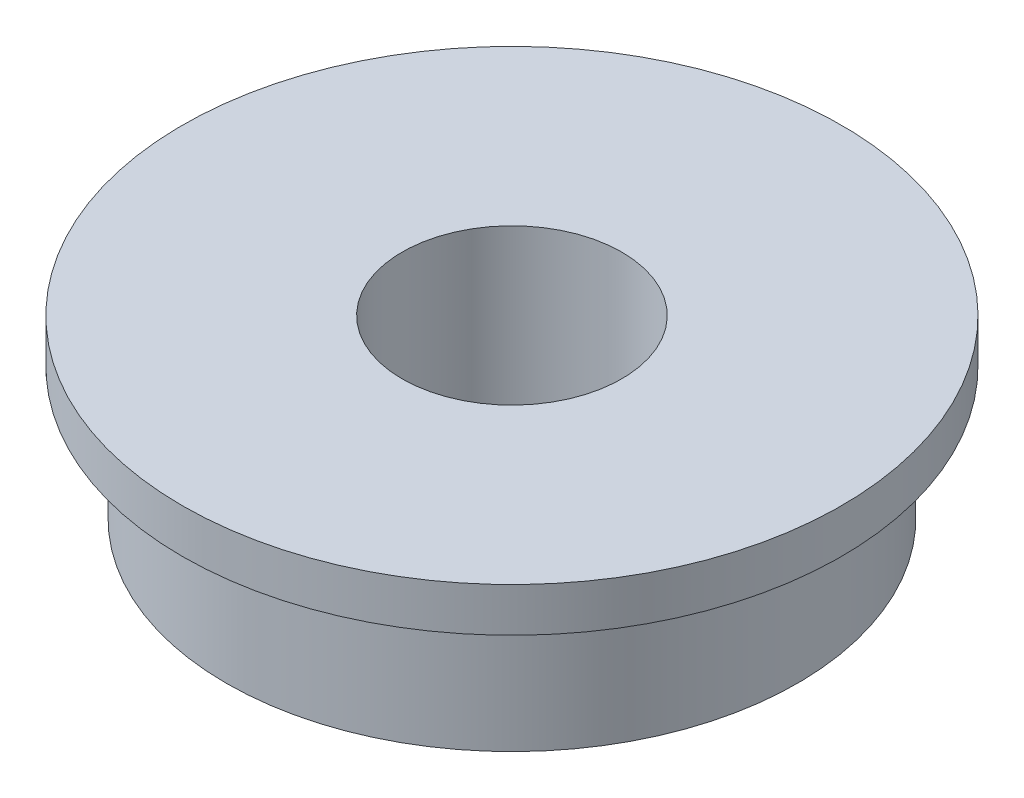
from build123d import *

# Parameters (mm, degrees)
SKETCH1_R           = 6.5
SKETCH1_R_2         = 2.5
BOSS_EXTRUDE1_DEPTH = 2
SKETCH2_R           = 7.5
SKETCH2_R_2         = 6.5
BOSS_EXTRUDE2_DEPTH = 1


with BuildPart() as part:
    # Sketch1 → Boss-Extrude1 (new body, symmetric)
    with BuildSketch(Plane(origin=(0, 0, 0), x_dir=(1, 0, 0), z_dir=(0, 1, 0))):
        Circle(SKETCH1_R)
        Circle(SKETCH1_R_2, mode=Mode.SUBTRACT)
    extrude(amount=BOSS_EXTRUDE1_DEPTH, both=True)

    # Sketch2 → Boss-Extrude2 (add)
    with BuildSketch(Plane(origin=(0, 2, 0), x_dir=(1, 0, 0), z_dir=(0, 1, 0))):
        Circle(SKETCH2_R)
        Circle(SKETCH2_R_2, mode=Mode.SUBTRACT)
    extrude(amount=-BOSS_EXTRUDE2_DEPTH)


solid = part.part
